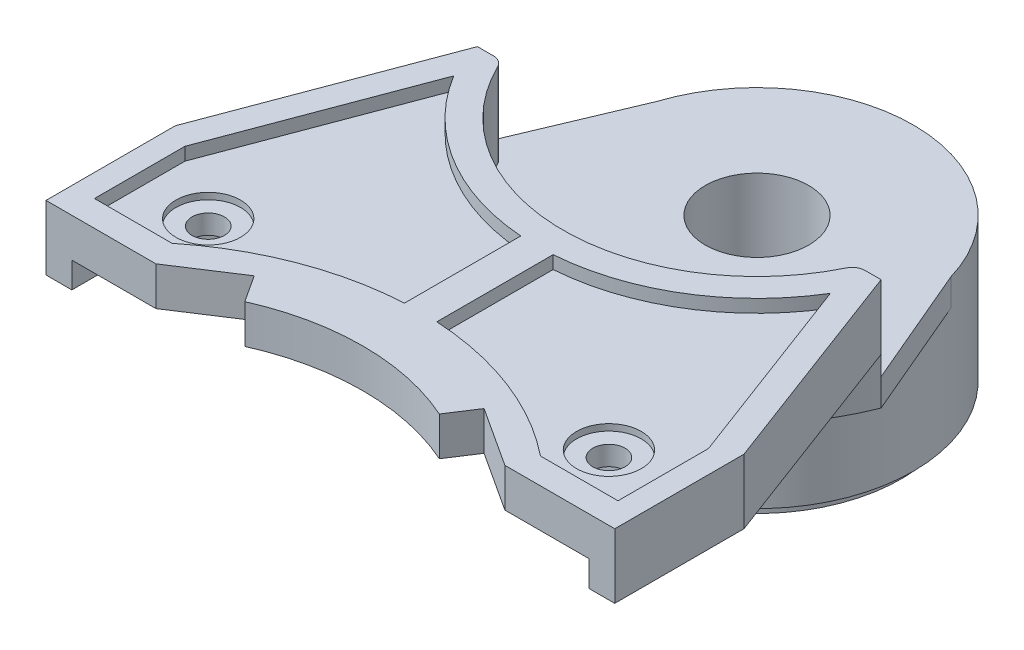
from build123d import *

# Parameters (mm, degrees)
BOSS_EXTRUDE1_DEPTH = 5
CUT_EXTRUDE6_DEPTH  = 2
CUT_EXTRUDE7_DEPTH  = 2
SKETCH12_R          = 16.732442385
BOSS_EXTRUDE3_DEPTH = 8.6
SKETCH13_R          = 12.1
SKETCH13_R_2        = 10.4
BOSS_EXTRUDE4_DEPTH = 10
SKETCH14_R          = 6
BOSS_EXTRUDE5_DEPTH = 10
CUT_EXTRUDE10_DEPTH = 1
SKETCH7_R           = 1.25
CUT_EXTRUDE11_DEPTH = 19.6
SKETCH8_R           = 2.5
CUT_EXTRUDE12_DEPTH = 1.5
SKETCH3_R           = 15
CUT_EXTRUDE14_DEPTH = 6.5
CUT_EXTRUDE15_DEPTH = 6.5
SKETCH15_R          = 1.25
CUT_EXTRUDE16_DEPTH = 6.5
FILLET2_R           = 1
SKETCH20_R          = 12.503929781
SKETCH20_R_2        = 11.15
CUT_EXTRUDE17_DEPTH = 1
SKETCH21_R          = 4
CUT_EXTRUDE19_DEPTH = 8.8
FILLET10_R          = 1
CUT_EXTRUDE21_DEPTH = 9.6


with BuildPart() as part:
    # Sketch1 → Boss-Extrude1 (new body)
    with BuildSketch(Plane(origin=(0, 0, 0), x_dir=(1, 0, 0), z_dir=(0, 1, 0))):
        with BuildLine():
            Line((-22, -23.004932369), (-22, -33.004932369))
            Line((-22, -33.004932369), (-13.5, -33.004932369))
            Line((-13.5, -33.004932369), (-8.890227771, -30.004932369))
            Line((-8.890227771, -30.004932369), (-7.526591408, -32.100283382))
            ThreePointArc((-7.526591408, -32.100283382), (-3.847417482, -30.904492858), (0, -30.5))
            Line((0, -30.5), (0, 12.5))
            ThreePointArc((0, 12.5), (-7.116131574, 10.276705281), (-11.700861907, 4.397707428))
            Line((-11.700861907, 4.397707428), (-22, -23.004932369))
        make_face()
        with BuildLine():
            ThreePointArc((11.700861907, 4.397707428), (7.116131574, 10.276705281), (0, 12.5))
            Line((0, 12.5), (0, -30.5))
            ThreePointArc((0, -30.5), (3.847417482, -30.904492858), (7.526591408, -32.100283382))
            Line((7.526591408, -32.100283382), (8.890227771, -30.004932369))
            Line((8.890227771, -30.004932369), (13.5, -33.004932369))
            Line((13.5, -33.004932369), (22, -33.004932369))
            Line((22, -33.004932369), (22, -23.004932369))
            Line((22, -23.004932369), (11.700861907, 4.397707428))
        make_face()
    extrude(amount=BOSS_EXTRUDE1_DEPTH)

    # Sketch9 → Cut-Extrude6 (cut)
    with BuildSketch(Plane.XZ):
        with BuildLine():
            Line((20, 33.004932369), (20, 27.004932369))
            ThreePointArc((20, 27.004932369), (0, 18), (-20, 27.004932369))
            Line((-20, 27.004932369), (-20, 33.004932369))
            Line((-20, 33.004932369), (20, 33.004932369))
        make_face()
    extrude(amount=-CUT_EXTRUDE6_DEPTH, mode=Mode.SUBTRACT)

    # Sketch11 → Cut-Extrude7 (cut)
    with BuildSketch(Plane.XZ):
        with BuildLine():
            Line((-20, 23.004932369), (-10.073125454, -3.40723582))
            ThreePointArc((-10.073125454, -3.40723582), (0, -10.633772254), (10.073125454, -3.40723582))
            Line((10.073125454, -3.40723582), (20, 23.004932369))
            Line((20, 23.004932369), (20, 25.529642354))
            ThreePointArc((20, 25.529642354), (0, 17.000016389), (-20, 25.529642354))
            Line((-20, 25.529642354), (-20, 23.004932369))
        make_face()
    extrude(amount=-CUT_EXTRUDE7_DEPTH, mode=Mode.SUBTRACT)

    # Sketch12 → Boss-Extrude3 (add)
    with BuildSketch(Plane.XZ.offset(-5)):
        Circle(SKETCH12_R)
    extrude(amount=BOSS_EXTRUDE3_DEPTH)

    # Sketch13 → Boss-Extrude4 (add)
    with BuildSketch(Plane.XZ.offset(3.6)):
        Circle(SKETCH13_R)
        Circle(SKETCH13_R_2, mode=Mode.SUBTRACT)
    extrude(amount=BOSS_EXTRUDE4_DEPTH)

    # Sketch14 → Boss-Extrude5 (add)
    with BuildSketch(Plane.XZ.offset(3.6)):
        Circle(SKETCH14_R)
    extrude(amount=BOSS_EXTRUDE5_DEPTH)

    # Sketch6 → Cut-Extrude10 (cut)
    with BuildSketch(Plane(origin=(0, 5, 0), x_dir=(1, 0, 0), z_dir=(0, 1, 0))):
        with BuildLine():
            Line((-1.251136393, -17.022628361), (-1.251136393, -26.022628361))
            ThreePointArc((-1.251136393, -26.022628361), (-8.141618616, -27.494920638), (-14.251136393, -31.004932369))
            Line((-14.251136393, -31.004932369), (-20.251136393, -31.004932369))
            Line((-20.251136393, -31.004932369), (-20.251136393, -24.004932369))
            Line((-20.251136393, -24.004932369), (-14.570404486, -8.89036173))
            ThreePointArc((-14.570404486, -8.89036173), (-8.894589877, -14.567823774), (-1.251136393, -17.022628361))
        make_face()
        with BuildLine():
            Line((20.251136393, -24.004932369), (14.570404486, -8.89036173))
            ThreePointArc((14.570404486, -8.89036173), (8.894589877, -14.567823774), (1.251136393, -17.022628361))
            Line((1.251136393, -17.022628361), (1.251136393, -26.022628361))
            ThreePointArc((1.251136393, -26.022628361), (8.141618616, -27.494920638), (14.251136393, -31.004932369))
            Line((14.251136393, -31.004932369), (20.251136393, -31.004932369))
            Line((20.251136393, -31.004932369), (20.251136393, -24.004932369))
        make_face()
    extrude(amount=-CUT_EXTRUDE10_DEPTH, mode=Mode.SUBTRACT)

    # Sketch7 → Cut-Extrude11 (cut, through all)
    with BuildSketch(Plane(origin=(0, 5, 0), x_dir=(1, 0, 0), z_dir=(0, 1, 0))):
        with Locations((-15.5, -26.954932369)):
            Circle(SKETCH7_R)
        with Locations((15.5, -26.954932369)):
            Circle(SKETCH7_R)
    extrude(amount=-CUT_EXTRUDE11_DEPTH, mode=Mode.SUBTRACT)

    # Sketch8 → Cut-Extrude12 (cut)
    with BuildSketch(Plane(origin=(0, 5, 0), x_dir=(1, 0, 0), z_dir=(0, 1, 0))):
        with Locations((-15.5, -26.954932369)):
            Circle(SKETCH8_R)
        with Locations((15.5, -26.954932369)):
            Circle(SKETCH8_R)
    extrude(amount=-CUT_EXTRUDE12_DEPTH, mode=Mode.SUBTRACT)

    # Sketch3 → Cut-Extrude14 (cut)
    with BuildSketch(Plane(origin=(0, 5, 0), x_dir=(1, 0, 0), z_dir=(0, 1, 0))):
        Circle(SKETCH3_R)
    extrude(amount=-CUT_EXTRUDE14_DEPTH, mode=Mode.SUBTRACT)

    # Sketch19 → Cut-Extrude15 (cut)
    with BuildSketch(Plane(origin=(0, 5, 0), x_dir=(1, 0, 0), z_dir=(0, 1, 0))):
        with BuildLine():
            Line((-15.614173224, -6.014334769), (15.614173224, -6.014334769))
            ThreePointArc((15.614173224, -6.014334769), (0, 16.732442385), (-15.614173224, -6.014334769))
        make_face()
    extrude(amount=-CUT_EXTRUDE15_DEPTH, mode=Mode.SUBTRACT)

    # Sketch15 → Cut-Extrude16 (cut)
    with BuildSketch(Plane.XZ.offset(13.6)):
        Circle(SKETCH15_R)
    extrude(amount=-CUT_EXTRUDE16_DEPTH, mode=Mode.SUBTRACT)

    # Fillet2
    fillet2_edges = [part.edges().sort_by_distance(p)[0] for p in [
        (-6, -13.6, 0),
    ]]
    fillet(fillet2_edges, radius=FILLET2_R)

    # Sketch20 → Cut-Extrude17 (cut)
    with BuildSketch(Plane.XZ.offset(13.6)):
        Circle(SKETCH20_R)
        Circle(SKETCH20_R_2, mode=Mode.SUBTRACT)
    extrude(amount=-CUT_EXTRUDE17_DEPTH, mode=Mode.SUBTRACT)

    # Sketch21 → Cut-Extrude19 (cut)
    with BuildSketch(Plane(origin=(0, -1.5, 0), x_dir=(1, 0, 0), z_dir=(0, 1, 0))):
        Circle(SKETCH21_R)
    extrude(amount=-CUT_EXTRUDE19_DEPTH, mode=Mode.SUBTRACT)

    # Fillet10
    fillet10_edges = [part.edges().sort_by_distance(p)[0] for p in [
        (13.741461978, 1.75, 6.014334769),
        (-13.741461978, 1.75, 6.014334769),
    ]]
    fillet(fillet10_edges, radius=FILLET10_R)

    # Sketch22 → Cut-Extrude21 (cut, through all)
    with BuildSketch(Plane.XZ.offset(3.6)):
        with BuildLine():
            Line((15.614173224, 6.014334769), (11.615625162, -3.389284894))
            ThreePointArc((11.615625162, -3.389284894), (0.193858429, -12.098446963), (-11.501074122, -3.759693345))
            Line((-11.501074122, -3.759693345), (-15.614173224, 6.014334769))
            ThreePointArc((-15.614173224, 6.014334769), (0, -16.732442385), (15.614173224, 6.014334769))
        make_face()
    extrude(amount=-CUT_EXTRUDE21_DEPTH, mode=Mode.SUBTRACT)


solid = part.part
